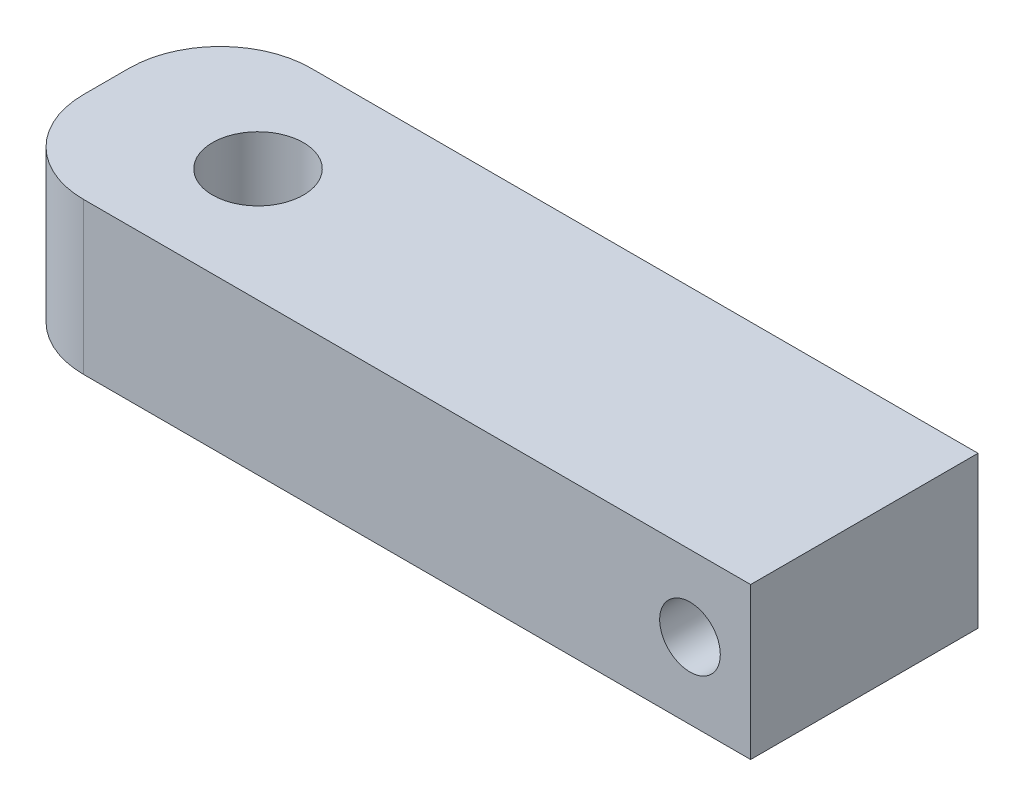
from build123d import *

# Parameters (mm, degrees)
SKETCH1_W           = 63.5
SKETCH1_H           = 12.7
SKETCH1_R           = 2.54
BOSS_EXTRUDE1_DEPTH = 19.05
CUT_EXTRUDE1_REACH  = 14.7
SKETCH2_R           = 3.81
FILLET1_R           = 7.62


with BuildPart() as part:
    # Sketch1 → Boss-Extrude1 (new body)
    with BuildSketch(Plane.XY):
        Rectangle(SKETCH1_W, SKETCH1_H)
        with Locations((26.67, 0)):
            Circle(SKETCH1_R, mode=Mode.SUBTRACT)
    extrude(amount=BOSS_EXTRUDE1_DEPTH)

    # Sketch2 → Cut-Extrude1 (cut, up to next)
    with BuildSketch(Plane(origin=(0, 6.35, 0), x_dir=(1, 0, 0), z_dir=(0, 1, 0)), mode=Mode.PRIVATE) as cut_extrude1_sk1:
        with Locations((-19.05, -9.525)):
            Circle(SKETCH2_R)
    cut_extrude1_tool1 = extrude(cut_extrude1_sk1.sketch, amount=-CUT_EXTRUDE1_REACH, mode=Mode.PRIVATE) & part.part
    add(cut_extrude1_tool1.solids().sort_by_distance((-19.05, 6.35, 9.525))[0], mode=Mode.SUBTRACT)

    # Fillet1
    fillet1_edges = [part.edges().sort_by_distance(p)[0] for p in [
        (-31.75, 0, 19.05),
        (-31.75, 0, 0),
    ]]
    fillet(fillet1_edges, radius=FILLET1_R)


solid = part.part
